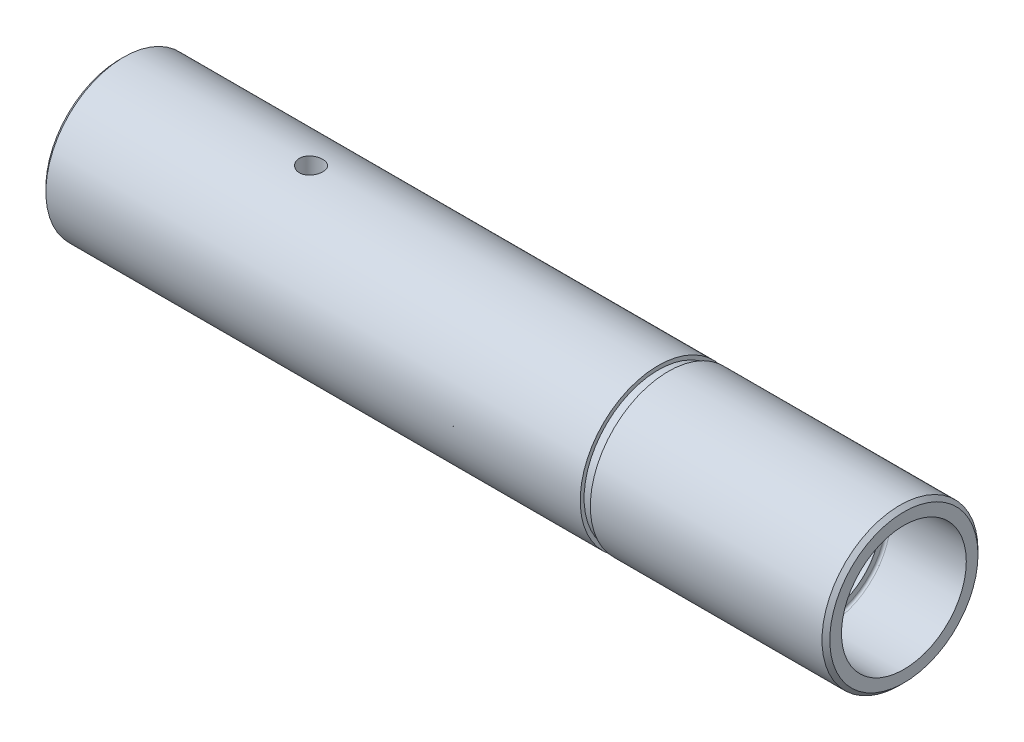
from build123d import *

# Parameters (mm, degrees)
SKETCH1_R           = 10
SKETCH1_R_2         = 7
BOSS_EXTRUDE1_DEPTH = 100.5
SKETCH2_R           = 8
CUT_EXTRUDE1_DEPTH  = 10
SKETCH3_R           = 8
CUT_EXTRUDE2_DEPTH  = 10
SKETCH4_W           = 1.3
SKETCH4_H           = 0.5
SKETCH5_R           = 1.5
CUT_EXTRUDE3_DEPTH  = 10
CHAMFER1_SIZE       = 0.5
FILLET1_R           = 0.3


with BuildPart() as part:
    # Sketch1 → Boss-Extrude1 (new body)
    with BuildSketch(Plane(origin=(0, 0, 0), x_dir=(0, 0, -1), z_dir=(1, 0, 0))):
        Circle(SKETCH1_R)
        Circle(SKETCH1_R_2, mode=Mode.SUBTRACT)
    extrude(amount=BOSS_EXTRUDE1_DEPTH)

    # Sketch2 → Cut-Extrude1 (cut)
    with BuildSketch(Plane.ZY):
        Circle(SKETCH2_R)
    extrude(amount=-CUT_EXTRUDE1_DEPTH, mode=Mode.SUBTRACT)

    # Sketch3 → Cut-Extrude2 (cut)
    with BuildSketch(Plane(origin=(100.5, 0, 0), x_dir=(0, 0, -1), z_dir=(1, 0, 0))):
        Circle(SKETCH3_R)
    extrude(amount=-CUT_EXTRUDE2_DEPTH, mode=Mode.SUBTRACT)

    # Sketch4 → Cut-Revolve1 (revolve, cut)
    with BuildSketch(Plane.XY):
        with Locations((69.65, 9.75)):
            Rectangle(SKETCH4_W, SKETCH4_H)
    revolve(axis=Axis((100.5, 0, 0), (-1, 0, 0)), mode=Mode.SUBTRACT)

    # Sketch5 → Cut-Extrude3 (cut, symmetric)
    with BuildSketch(Plane(origin=(0, 0, 0), x_dir=(1, 0, 0), z_dir=(0, 1, 0))):
        with Locations((24.5, 0)):
            Circle(SKETCH5_R)
    extrude(amount=CUT_EXTRUDE3_DEPTH, both=True, mode=Mode.SUBTRACT)

    # Chamfer1
    chamfer1_edges = [part.edges().sort_by_distance(p)[0] for p in [
        (0, 0, 10),
        (100.5, 0, 10),
    ]]
    chamfer(chamfer1_edges, length=CHAMFER1_SIZE)

    # Fillet1
    fillet1_edges = [part.edges().sort_by_distance(p)[0] for p in [
        (10, 0, -8),
        (90.5, 0, 8),
    ]]
    fillet(fillet1_edges, radius=FILLET1_R)


solid = part.part
